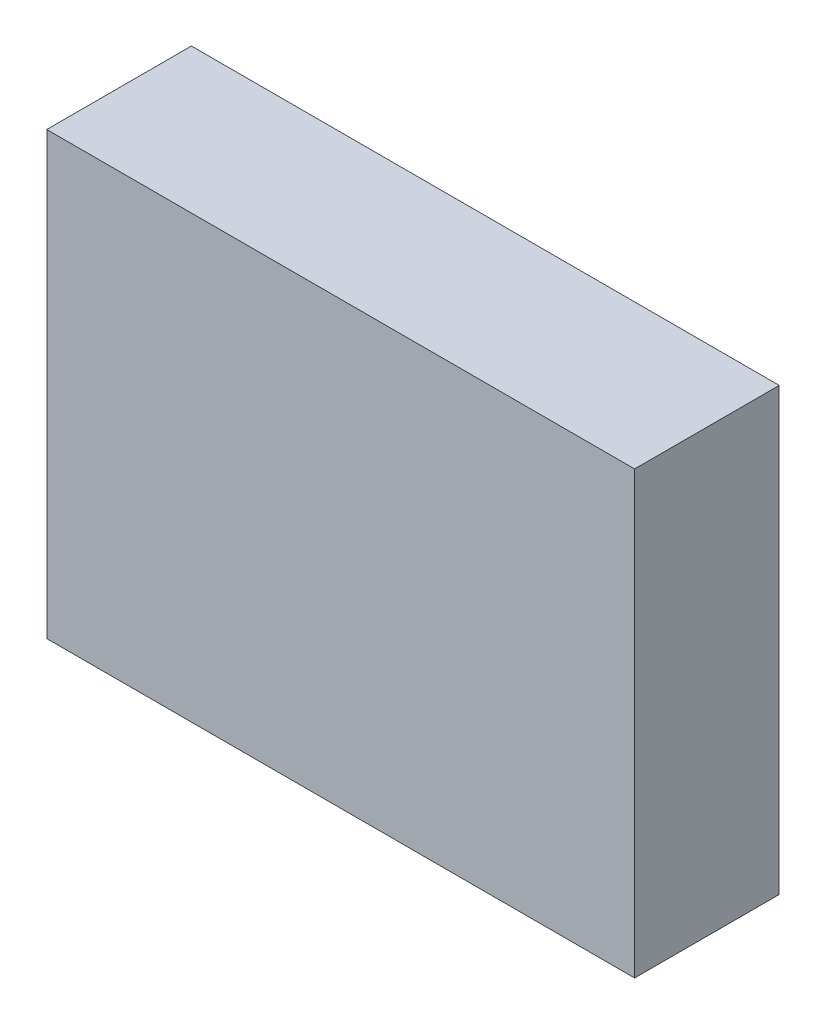
from build123d import *

# Parameters (mm, degrees)
SKETCH1_W               = 4.064
SKETCH1_H               = 3.048
COMPONENT_OUTLINE_DEPTH = 1


with BuildPart() as part:
    # Sketch1 → Component_Outline (new body)
    with BuildSketch(Plane.XY):
        Rectangle(SKETCH1_W, SKETCH1_H)
    extrude(amount=COMPONENT_OUTLINE_DEPTH)


solid = part.part
